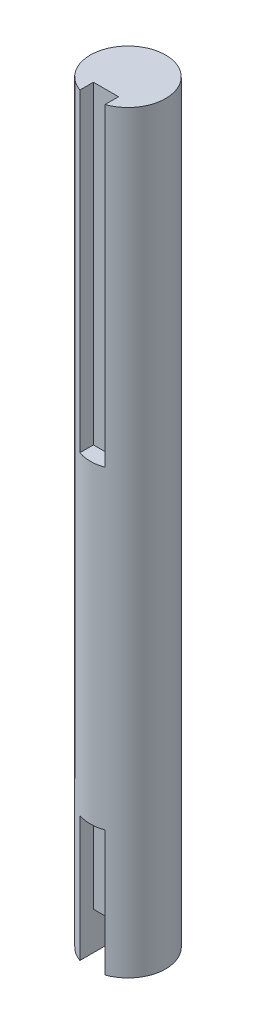
from build123d import *

# Parameters (mm, degrees)
SKETCH1_R                = 6
BOSS_EXTRUDE1_DEPTH      = 104
BOSS_EXTRUDE1_DEPTH_BACK = 16
CUT_EXTRUDE3_START       = -16
SKETCH2_W                = 4
SKETCH2_H                = 5
CUT_EXTRUDE3_DEPTH       = 20
CUT_EXTRUDE3_DEPTH_BACK  = 0.0001
CUT_EXTRUDE4_START       = 104
SKETCH2_2_W              = 4
SKETCH2_2_H              = 5
CUT_EXTRUDE4_DEPTH       = 50
CUT_EXTRUDE6_START       = -16
SKETCH3_W                = 4
SKETCH3_H                = 10
CUT_EXTRUDE6_DEPTH       = 6


with BuildPart() as part:
    # Sketch1 → Boss-Extrude1 (new body, two sides)
    with BuildSketch(Plane(origin=(0, 0, 0), x_dir=(1, 0, 0), z_dir=(0, 1, 0))) as boss_extrude1_sk:
        Circle(SKETCH1_R)
    extrude(amount=BOSS_EXTRUDE1_DEPTH)
    extrude(boss_extrude1_sk.sketch, amount=-BOSS_EXTRUDE1_DEPTH_BACK)

    # Sketch2 → Cut-Extrude3 (cut, two sides)
    with BuildSketch(Plane(origin=(0, 0, 0), x_dir=(1, 0, 0), z_dir=(0, 1, 0)).offset(CUT_EXTRUDE3_START)) as cut_extrude3_sk:
        with Locations((0, -6)):
            Rectangle(SKETCH2_W, SKETCH2_H)
    extrude(amount=CUT_EXTRUDE3_DEPTH, mode=Mode.SUBTRACT)
    extrude(cut_extrude3_sk.sketch, amount=-CUT_EXTRUDE3_DEPTH_BACK, mode=Mode.SUBTRACT)

    # Sketch2_2 → Cut-Extrude4 (cut)
    with BuildSketch(Plane(origin=(0, 0, 0), x_dir=(1, 0, 0), z_dir=(0, 1, 0)).offset(CUT_EXTRUDE4_START)):
        with Locations((0, -6)):
            Rectangle(SKETCH2_2_W, SKETCH2_2_H)
    extrude(amount=-CUT_EXTRUDE4_DEPTH, mode=Mode.SUBTRACT)

    # Sketch3 → Cut-Extrude6 (cut)
    with BuildSketch(Plane(origin=(0, 0, 0), x_dir=(1, 0, 0), z_dir=(0, 1, 0)).offset(CUT_EXTRUDE6_START)):
        with Locations((0, -6)):
            Rectangle(SKETCH3_W, SKETCH3_H)
    extrude(amount=CUT_EXTRUDE6_DEPTH, mode=Mode.SUBTRACT)


solid = part.part
